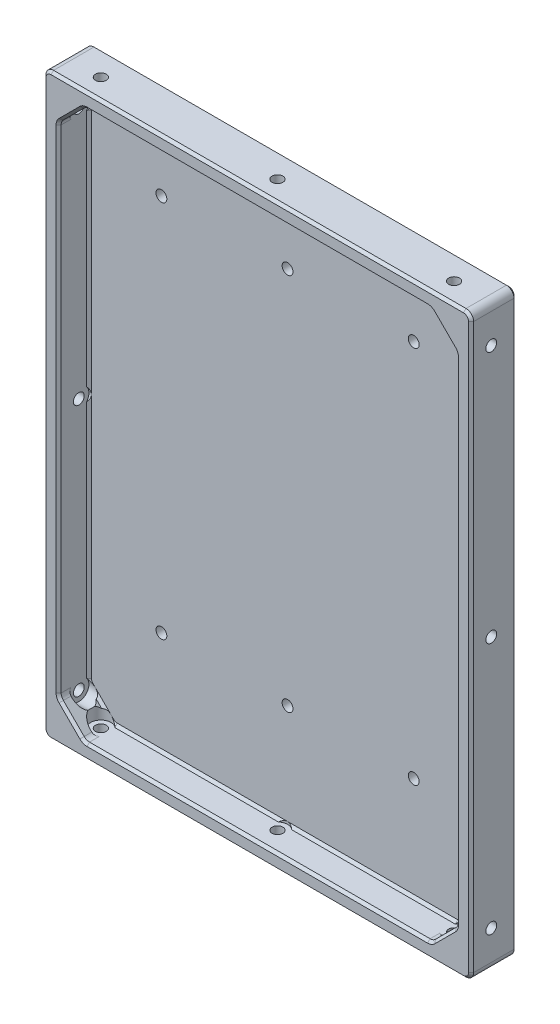
from build123d import *

# Parameters (mm, degrees)
SKETCH_1_W                   = 169.5
SKETCH_1_H                   = 229.5
EXTRUDE_1_DEPTH              = 6
SKETCH_2_W                   = 169.5
SKETCH_2_H                   = 229.5
SKETCH_2_W_2                 = 157.5
SKETCH_2_H_2                 = 217.5
EXTRUDE_2_DEPTH              = 12
CHAMFER_1_SIZE               = 10
FILLET_1_R                   = 3
CHAMFER_2_SIZE               = 1
FILLET_2_R                   = 3
CHAMFER_3_SIZE               = 1
HOLE_WIZARD_M4_1_D           = 4.3
HOLE_WIZARD_M4_1_DEPTH       = 16
HOLE_WIZARD_M4_1_CBORE_D     = 8
HOLE_WIZARD_M4_1_CBORE_DEPTH = 10
HOLE_WIZARD_M4_2_D           = 4.3
HOLE_WIZARD_M4_2_DEPTH       = 16
HOLE_WIZARD_M4_2_CBORE_D     = 8
HOLE_WIZARD_M4_2_CBORE_DEPTH = 10
HOLE_WIZARD_M4_1_2_D         = 4.3


with BuildPart() as part:
    # ｽｹｯﾁ1 → ﾎﾞｽ - 押し出し1 (new body)
    with BuildSketch(Plane.XY):
        Rectangle(SKETCH_1_W, SKETCH_1_H)
    extrude(amount=EXTRUDE_1_DEPTH)

    # ｽｹｯﾁ2 → ﾎﾞｽ - 押し出し2 (add)
    with BuildSketch(Plane.XY.offset(6)):
        Rectangle(SKETCH_2_W, SKETCH_2_H)
        Rectangle(SKETCH_2_W_2, SKETCH_2_H_2, mode=Mode.SUBTRACT)
    extrude(amount=EXTRUDE_2_DEPTH)

    # 面取り1
    chamfer_1_edges = [part.edges().sort_by_distance(p)[0] for p in [
        (-78.75, -108.75, 12),
        (78.75, -108.75, 12),
        (78.75, 108.75, 12),
        (-78.75, 108.75, 12),
    ]]
    chamfer(chamfer_1_edges, length=CHAMFER_1_SIZE)

    # ﾌｨﾚｯﾄ1
    fillet_1_edges = [part.edges().sort_by_distance(p)[0] for p in [
        (-78.75, 98.75, 12),
        (-78.75, -98.75, 12),
        (68.75, -108.75, 12),
        (-68.75, -108.75, 12),
        (78.75, 98.75, 12),
        (78.75, -98.75, 12),
        (-68.75, 108.75, 12),
        (68.75, 108.75, 12),
    ]]
    fillet(fillet_1_edges, radius=FILLET_1_R)

    # 面取り2
    chamfer_2_edges = [part.edges().sort_by_distance(p)[0] for p in [
        (0, 108.75, 6),
        (0, 108.75, 18),
        (73.75, 103.75, 18),
        (73.75, 103.75, 6),
        (-78.75, 0, 6),
        (-73.75, -103.75, 6),
        (0, -108.75, 6),
        (73.75, -103.75, 6),
        (78.75, 0, 6),
        (-73.75, 103.75, 6),
        (78.521638598, -98.65540961, 6),
        (68.65540961, -108.521638598, 6),
        (-68.65540961, -108.521638598, 6),
        (-78.521638598, -98.65540961, 6),
        (-78.521638598, 98.65540961, 6),
        (-68.65540961, 108.521638598, 6),
        (78.521638598, 98.65540961, 6),
        (68.65540961, 108.521638598, 6),
        (78.75, 0, 18),
        (-73.75, 103.75, 18),
        (-78.75, 0, 18),
        (-73.75, -103.75, 18),
        (0, -108.75, 18),
        (73.75, -103.75, 18),
        (68.65540961, 108.521638598, 18),
        (78.521638598, 98.65540961, 18),
        (-68.65540961, 108.521638598, 18),
        (-78.521638598, 98.65540961, 18),
        (-78.521638598, -98.65540961, 18),
        (-68.65540961, -108.521638598, 18),
        (68.65540961, -108.521638598, 18),
        (78.521638598, -98.65540961, 18),
    ]]
    chamfer(chamfer_2_edges, length=CHAMFER_2_SIZE)

    # ﾌｨﾚｯﾄ2
    fillet_2_edges = [part.edges().sort_by_distance(p)[0] for p in [
        (-84.75, 114.75, 9),
        (84.75, 114.75, 9),
        (84.75, -114.75, 9),
        (-84.75, -114.75, 9),
    ]]
    fillet(fillet_2_edges, radius=FILLET_2_R)

    # 面取り3
    chamfer_3_edges = [part.edges().sort_by_distance(p)[0] for p in [
        (0, 114.75, 0),
        (0, 114.75, 18),
        (-84.75, 0, 0),
        (84.75, 0, 0),
        (0, -114.75, 0),
        (-83.871320344, -113.871320344, 0),
        (83.871320344, -113.871320344, 0),
        (-83.871320344, 113.871320344, 0),
        (83.871320344, 113.871320344, 0),
        (84.75, 0, 18),
        (-84.75, 0, 18),
        (0, -114.75, 18),
        (-83.871320344, -113.871320344, 18),
        (83.871320344, -113.871320344, 18),
        (-83.871320344, 113.871320344, 18),
        (83.871320344, 113.871320344, 18),
    ]]
    chamfer(chamfer_3_edges, length=CHAMFER_3_SIZE)

    # Hole Wizard M4 _1
    with Locations(Plane(origin=(-68.75, 0, 0), x_dir=(0, 0, -1), z_dir=(1, 0, 0))):
        with Locations((-10, 0), (-10, 100), (-10, -100)):
            hole_wizard_m4_1 = CounterBoreHole(HOLE_WIZARD_M4_1_D / 2, HOLE_WIZARD_M4_1_CBORE_D / 2, HOLE_WIZARD_M4_1_CBORE_DEPTH, depth=HOLE_WIZARD_M4_1_DEPTH)

    # ﾐﾗｰ1: Hole Wizard M4 _1 across plane
    add(hole_wizard_m4_1.mirror(Plane(origin=(0, 0, 0), x_dir=(0, 0, 1), z_dir=(1, 0, 0))), mode=Mode.SUBTRACT)

    # M4 六角穴付き頭ねじ用座ぐり穴2
    with Locations(Plane(origin=(0, 98.75, 0), x_dir=(-1, 0, 0), z_dir=(0, -1, 0))):
        with Locations((-70, -10), (70, -10), (0, -10)):
            hole_wizard_m4_2 = CounterBoreHole(HOLE_WIZARD_M4_2_D / 2, HOLE_WIZARD_M4_2_CBORE_D / 2, HOLE_WIZARD_M4_2_CBORE_DEPTH, depth=HOLE_WIZARD_M4_2_DEPTH)

    # ﾐﾗｰ2: M4 六角穴付き頭ねじ用座ぐり穴2 across plane
    add(hole_wizard_m4_2.mirror(Plane.ZX), mode=Mode.SUBTRACT)

    # Hole Wizard M4 _1 2 (through all)
    with Locations(Plane.XY.offset(6)):
        with Locations((0, 82), (50, 82), (50, -68), (0, -68), (-50, 82), (-50, -68)):
            Hole(HOLE_WIZARD_M4_1_2_D / 2)


solid = part.part
